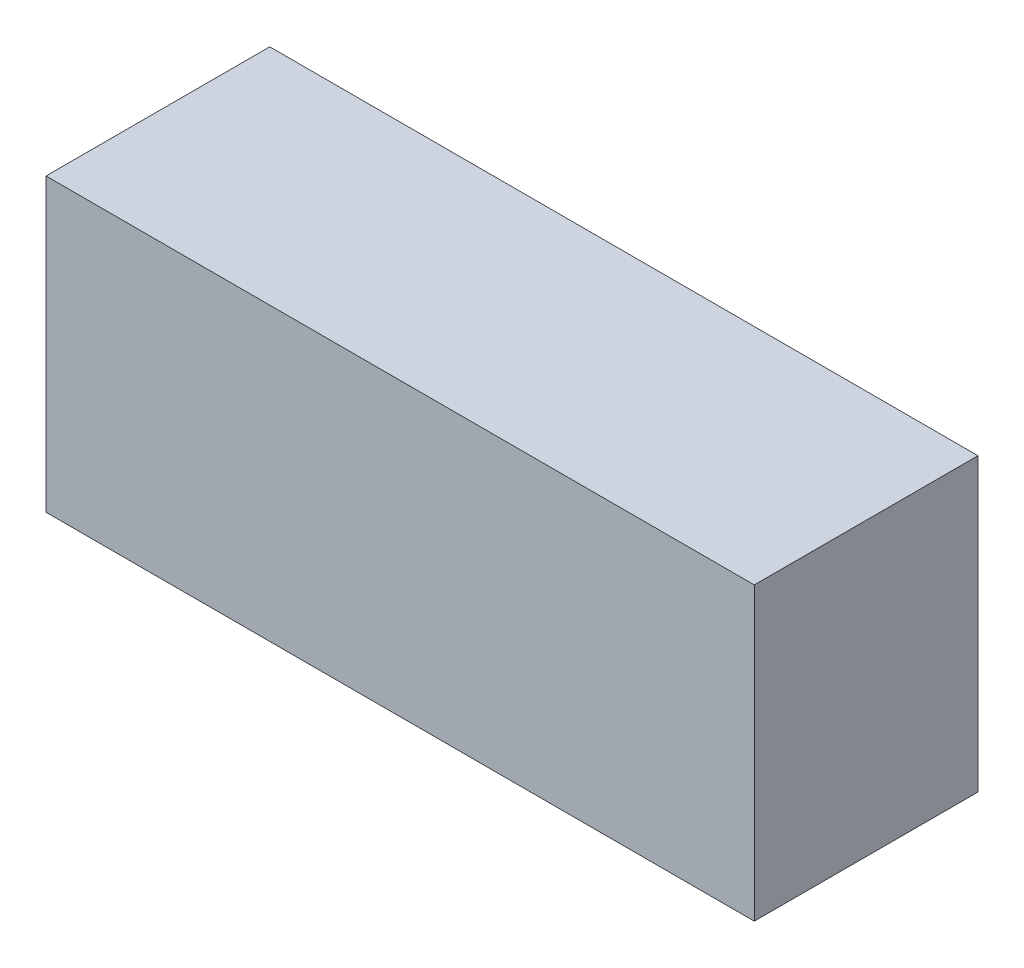
from build123d import *

# Parameters (mm, degrees)
SKETCH1_W           = 135.89
SKETCH1_H           = 42.926
BOSS_EXTRUDE1_DEPTH = 55.88


with BuildPart() as part:
    # Sketch1 → Boss-Extrude1 (new body)
    with BuildSketch(Plane(origin=(0, 0, 0), x_dir=(1, 0, 0), z_dir=(0, 1, 0))):
        Rectangle(SKETCH1_W, SKETCH1_H)
    extrude(amount=BOSS_EXTRUDE1_DEPTH)


solid = part.part
